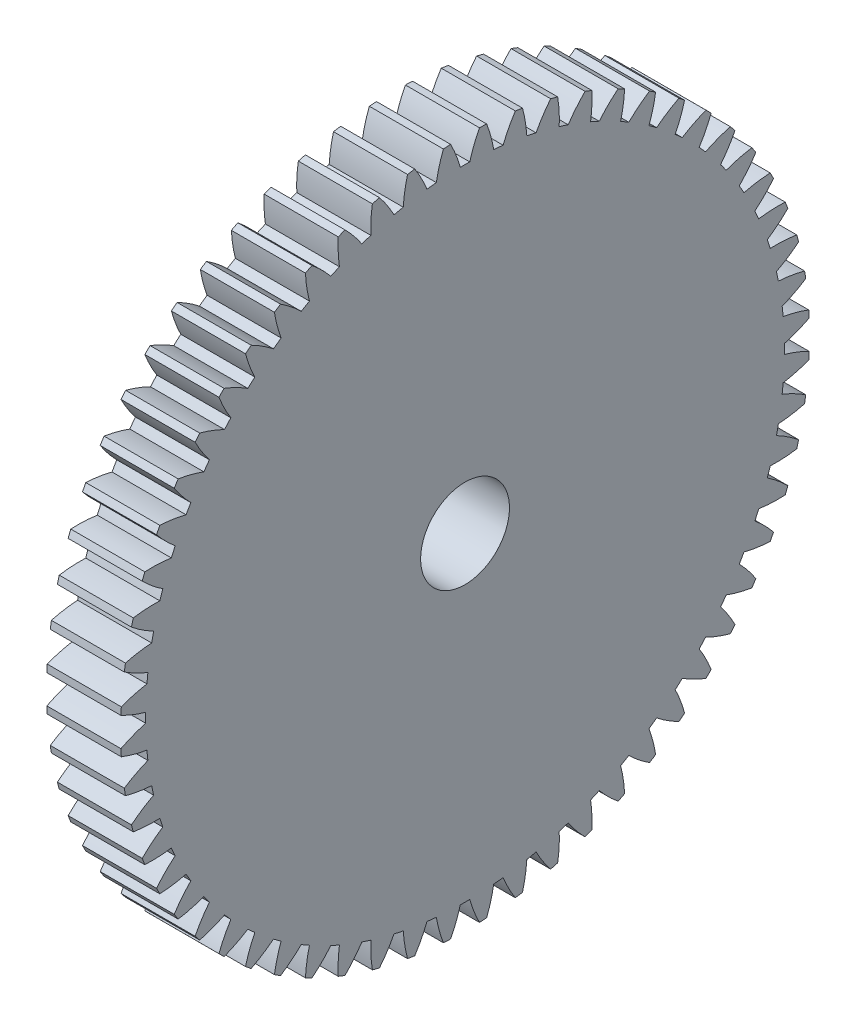
from build123d import *

# Parameters (mm, degrees)
BASPROSKE_W     = 10
BASPROSKE_H     = 46.5
TOOTHCUT_DEPTH  = 67.516915142
TEETHCUTS_COUNT = 60
TEETHCUTS_ANGLE = 354
BORSKE_R        = 6
BORE_DEPTH      = 50.0000508


with BuildPart() as part:
    # BasProSke → Base-Revolve (revolve)
    with BuildSketch(Plane(origin=(0, 0, 0), x_dir=(1, 0, 0), z_dir=(0, 1, 0)), mode=Mode.PRIVATE) as base_revolve_sk:
        with Locations((5, 23.25)):
            Rectangle(BASPROSKE_W, BASPROSKE_H)
    revolve(base_revolve_sk.sketch.rotate(Axis((-10, 0, 0), (1, 0, 0)), 180), axis=Axis((-10, 0, 0), (1, 0, 0)))

    # TooCutSke → ToothCut (cut, through all)
    with BuildSketch(Plane(origin=(0, 0, 0), x_dir=(0, 0, -1), z_dir=(1, 0, 0))):
        with BuildLine():
            ThreePointArc((0.638657789, 43.119270544), (0, 43.124), (-0.638657789, 43.119270544))
            ThreePointArc((-0.638657789, 43.119270544), (-1.21237986, 44.83490593), (-1.955410142, 46.484289995))
            ThreePointArc((-1.955410142, 46.484289995), (0, 46.5254), (1.955410142, 46.484289995))
            ThreePointArc((1.955410142, 46.484289995), (1.21237986, 44.83490593), (0.638657789, 43.119270544))
        make_face()
    toothcut = extrude(amount=TOOTHCUT_DEPTH, mode=Mode.SUBTRACT)

    # TeethCuts: ToothCut ×60 about axis
    teethcuts_axis = Axis((-10, 0, 0), (1, 0, 0))
    for i in range(1, TEETHCUTS_COUNT):
        add(toothcut.rotate(teethcuts_axis, i * TEETHCUTS_ANGLE / (TEETHCUTS_COUNT - 1)), mode=Mode.SUBTRACT)

    # BorSke → Bore (cut, symmetric)
    with BuildSketch(Plane(origin=(0, 0, 0), x_dir=(0, 0, -1), z_dir=(1, 0, 0))):
        with Locations(Location((0, 0, 0), (0, 0, 180))):
            Circle(BORSKE_R)
    extrude(amount=BORE_DEPTH, both=True, mode=Mode.SUBTRACT)


solid = part.part
